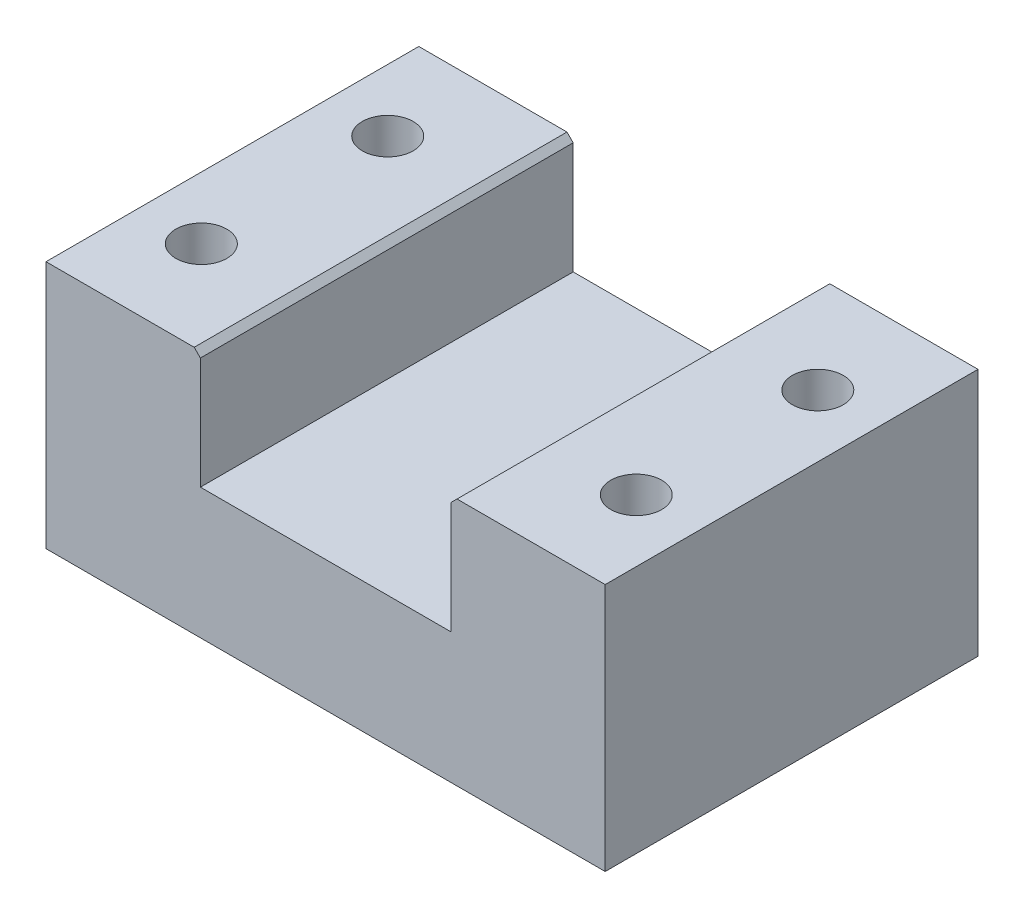
from build123d import *

# Parameters (mm, degrees)
SKETCH1_W           = 90
SKETCH1_H           = 60
BOSS_EXTRUDE1_DEPTH = 40
SKETCH2_W           = 40.3
SKETCH2_H           = 38
CUT_EXTRUDE1_DEPTH  = 61
SKETCH3_R           = 4.1
CUT_EXTRUDE2_DEPTH  = 41
CHAMFER1_SIZE       = 1


with BuildPart() as part:
    # Sketch1 → Boss-Extrude1 (new body)
    with BuildSketch(Plane(origin=(0, 0, 0), x_dir=(1, 0, 0), z_dir=(0, 1, 0))):
        Rectangle(SKETCH1_W, SKETCH1_H)
    extrude(amount=BOSS_EXTRUDE1_DEPTH)

    # Sketch2 → Cut-Extrude1 (cut, through all)
    with BuildSketch(Plane.XY.offset(30)):
        with Locations((0, 40)):
            Rectangle(SKETCH2_W, SKETCH2_H)
    extrude(amount=-CUT_EXTRUDE1_DEPTH, mode=Mode.SUBTRACT)

    # Sketch3 → Cut-Extrude2 (cut, through all)
    with BuildSketch(Plane.XZ):
        with Locations((-35, 15)):
            Circle(SKETCH3_R)
        with Locations((-35, -15)):
            Circle(SKETCH3_R)
        with Locations((35, -14.217273236)):
            Circle(SKETCH3_R)
        with Locations((35, 15)):
            Circle(SKETCH3_R)
    extrude(amount=-CUT_EXTRUDE2_DEPTH, mode=Mode.SUBTRACT)

    # Chamfer1
    chamfer1_edges = [part.edges().sort_by_distance(p)[0] for p in [
        (20.15, 40, 0),
        (-20.15, 40, 0),
    ]]
    chamfer(chamfer1_edges, length=CHAMFER1_SIZE)


solid = part.part
